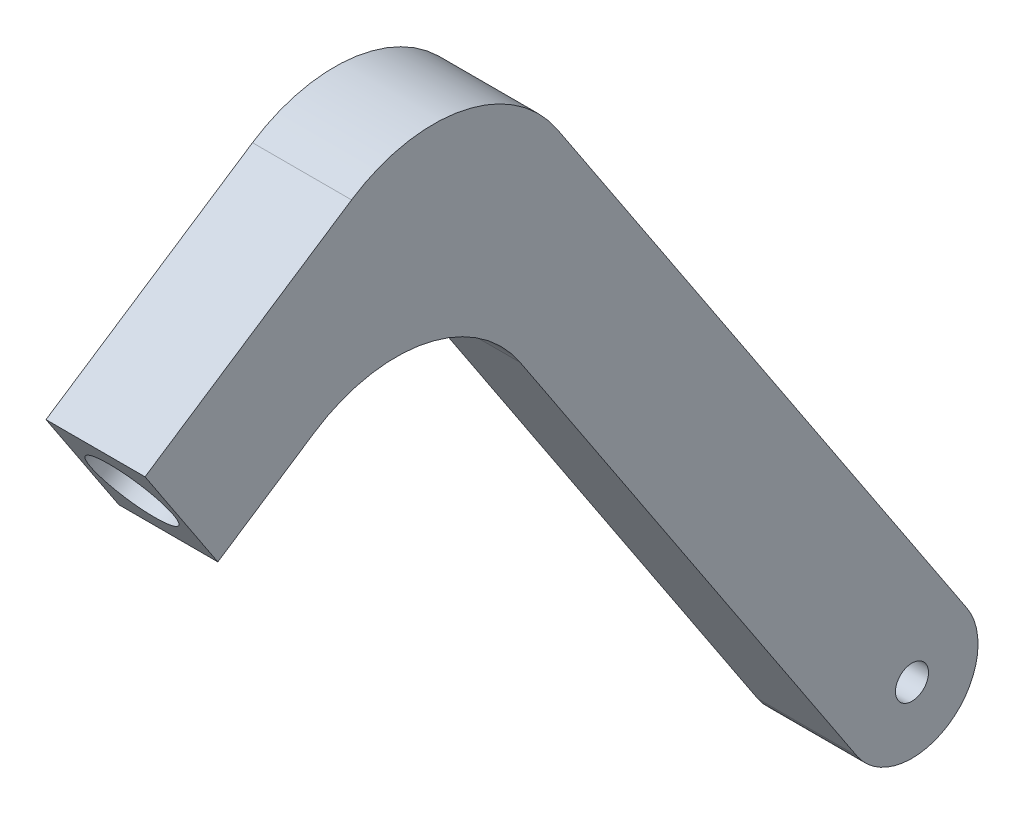
from build123d import *

# Parameters (mm, degrees)
SKETCH1_R           = 5
BOSS_EXTRUDE1_DEPTH = 30
SKETCH2_R           = 12.5
CUT_EXTRUDE1_DEPTH  = 20


with BuildPart() as part:
    # Sketch1 → Boss-Extrude1 (new body)
    with BuildSketch(Plane(origin=(0, 0, 0), x_dir=(0, 0, -1), z_dir=(1, 0, 0))):
        with BuildLine():
            Line((16.682027044, 11.032224332), (-107.430496688, 198.705028576))
            ThreePointArc((-107.430496688, 198.705028576), (-135.976276464, 217.975627767), (-169.787562283, 211.417084679))
            Line((-169.787562283, 211.417084679), (-232.345163698, 170.046243435))
            Line((-232.345163698, 170.046243435), (-210.280715034, 136.682189347))
            Line((-210.280715034, 136.682189347), (-181.087167707, 155.988581927))
            ThreePointArc((-181.087167707, 155.988581927), (-147.275881888, 162.547125016), (-118.730102112, 143.276525825))
            Line((-118.730102112, 143.276525825), (-16.682027044, -11.032224332))
            ThreePointArc((-16.682027044, -11.032224332), (11.032224332, -16.682027044), (16.682027044, 11.032224332))
        make_face()
        Circle(SKETCH1_R, mode=Mode.SUBTRACT)
    extrude(amount=BOSS_EXTRUDE1_DEPTH)

    # Sketch2 → Cut-Extrude1 (cut)
    with BuildSketch(Plane(origin=(0, -55.161121659, 83.41013522), x_dir=(1, 0, 0), z_dir=(0, -0.551611217, 0.834101352))):
        with Locations((15, 250)):
            Circle(SKETCH2_R)
    extrude(amount=-CUT_EXTRUDE1_DEPTH, mode=Mode.SUBTRACT)


solid = part.part
